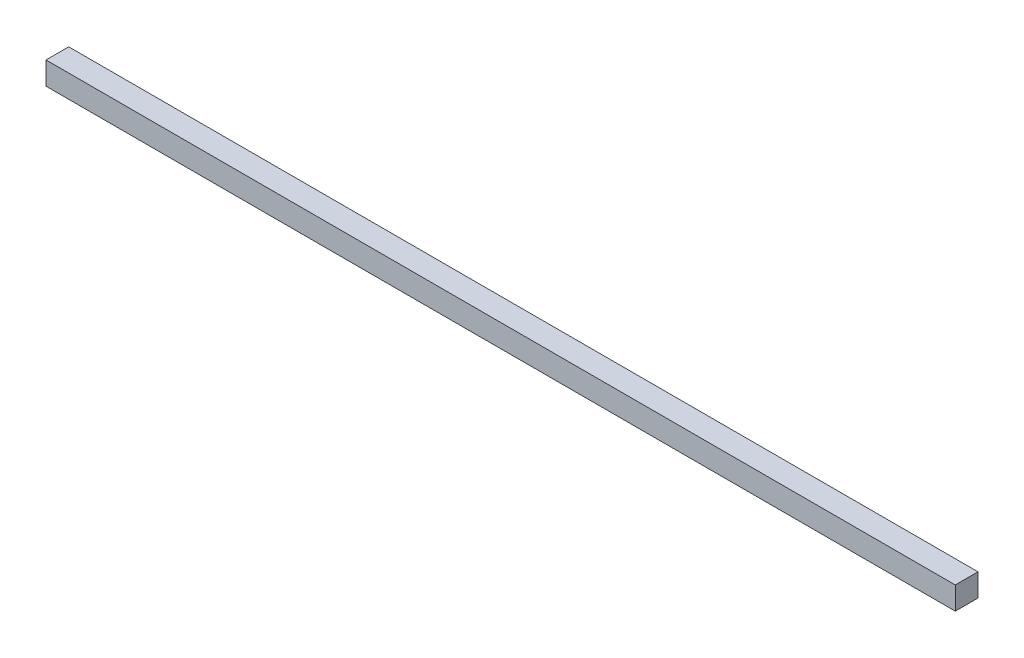
from build123d import *

# Parameters (mm, degrees)
SKETCH1_W           = 400
SKETCH1_H           = 10
BOSS_EXTRUDE1_DEPTH = 10


with BuildPart() as part:
    # Sketch1 → Boss-Extrude1 (new body)
    with BuildSketch(Plane(origin=(0, 0, 0), x_dir=(1, 0, 0), z_dir=(0, 1, 0))):
        Rectangle(SKETCH1_W, SKETCH1_H)
    extrude(amount=BOSS_EXTRUDE1_DEPTH)


solid = part.part
